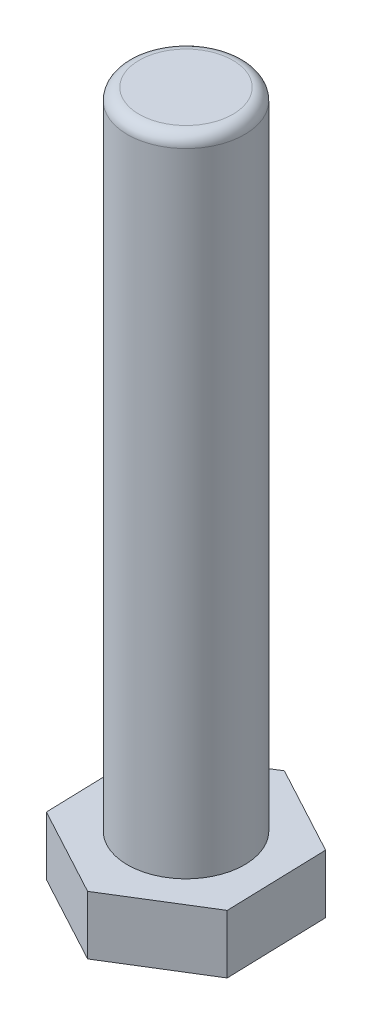
from build123d import *

# Parameters (mm, degrees)
BOSS_EXTRU_1_DEPTH = 10
ESQUISSE2_R        = 10
BOSS_EXTRU_2_DEPTH = 110
CONG_1_R           = 2


with BuildPart() as part:
    # Esquisse1 → Boss.-Extru.1 (new body)
    with BuildSketch(Plane(origin=(0, 0, 0), x_dir=(1, 0, 0), z_dir=(0, 1, 0))):
        Polygon((14.736253584, 9.101803684), (-0.514266419, 17.312871803), (-15.250520003, 8.211068118), (-14.736253584, -9.101803684), (0.514266419, -17.312871803), (15.250520003, -8.211068118), align=None)
    extrude(amount=BOSS_EXTRU_1_DEPTH)

    # Esquisse2 → Boss.-Extru.2 (add)
    with BuildSketch(Plane(origin=(0, 10, 0), x_dir=(1, 0, 0), z_dir=(0, 1, 0))):
        Circle(ESQUISSE2_R)
    extrude(amount=BOSS_EXTRU_2_DEPTH)

    # Congé1
    cong_1_edges = [part.edges().sort_by_distance(p)[0] for p in [
        (-10, 120, 0),
    ]]
    fillet(cong_1_edges, radius=CONG_1_R)


solid = part.part
